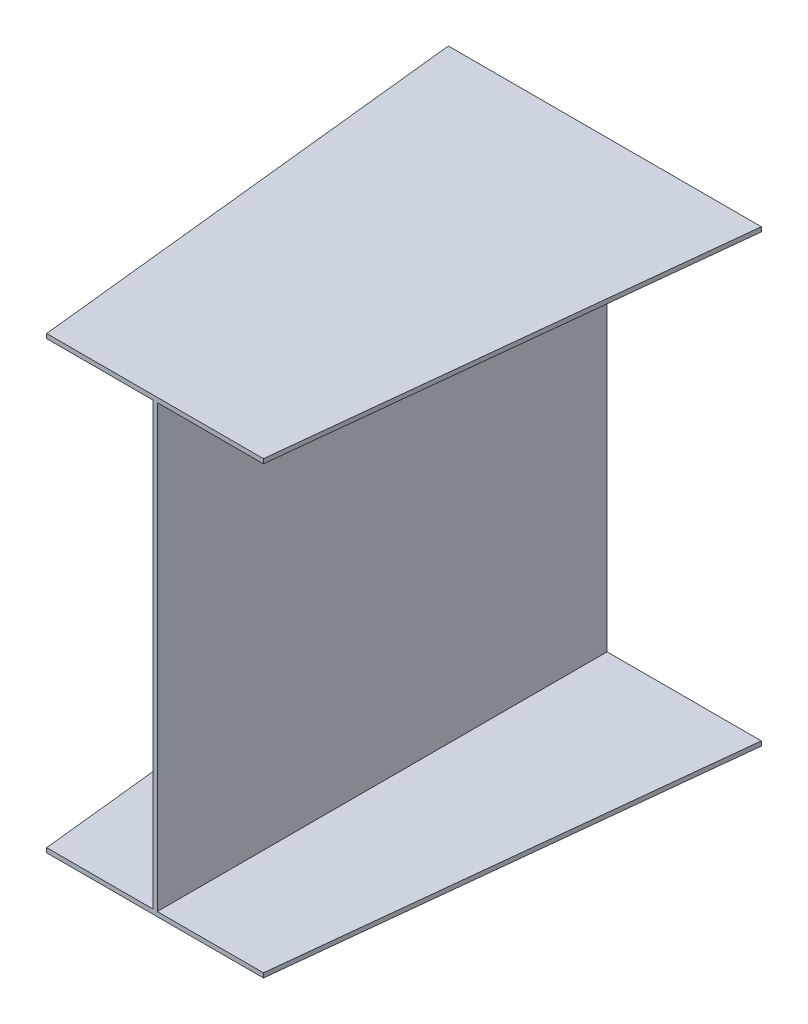
from build123d import *


with BuildPart() as part:
    # Sketch1 → Loft3 section 0
    with BuildSketch(Plane.XY):
        Polygon((10, 980), (353, 980), (353, 990), (-343, 990), (-343, 980), (0, 980), (0, 0), (-343, 0), (-343, -10), (353, -10), (353, 0), (10, 0), align=None)
    # Sketch4 → Loft3 section 1
    with BuildSketch(Plane.XY.offset(1000)):
        Polygon((0, 0), (0, 980), (-236, 980), (-236, 990), (246, 990), (246, 980), (10, 980), (10, 0), (246, 0), (246, -10), (-236, -10), (-236, 0), align=None)
    loft()


solid = part.part
